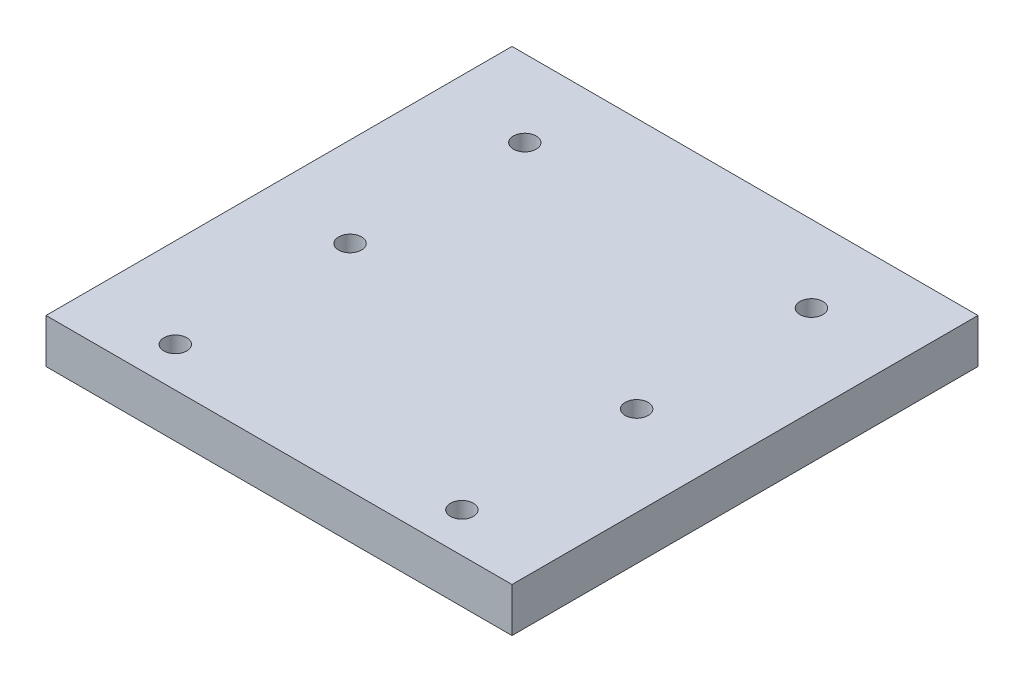
from build123d import *

# Parameters (mm, degrees)
SKETCH1_W           = 50.8
SKETCH1_H           = 50.8
BOSS_EXTRUDE1_DEPTH = 4.826
SKETCH2_R           = 1.25
CUT_EXTRUDE1_DEPTH  = 9.906
LPATTERN1_COUNT     = 3
LPATTERN1_PITCH     = 19.05


with BuildPart() as part:
    # Sketch1 → Boss-Extrude1 (new body)
    with BuildSketch(Plane(origin=(0, 0, 0), x_dir=(1, 0, 0), z_dir=(0, 1, 0))):
        Rectangle(SKETCH1_W, SKETCH1_H)
    extrude(amount=-BOSS_EXTRUDE1_DEPTH)

    # Sketch2 → Cut-Extrude1 (cut)
    with BuildSketch(Plane(origin=(0, 0, 0), x_dir=(1, 0, 0), z_dir=(0, 1, 0))):
        with Locations((-15.621, 17.018)):
            Circle(SKETCH2_R)
        with Locations((15.621, 17.018)):
            Circle(SKETCH2_R)
    cut_extrude1 = extrude(amount=-CUT_EXTRUDE1_DEPTH, mode=Mode.SUBTRACT)

    # LPattern1: Cut-Extrude1 ×3
    with Locations(*[(0, 0, i * LPATTERN1_PITCH) for i in range(1, LPATTERN1_COUNT)]):
        add(cut_extrude1, mode=Mode.SUBTRACT)


solid = part.part
